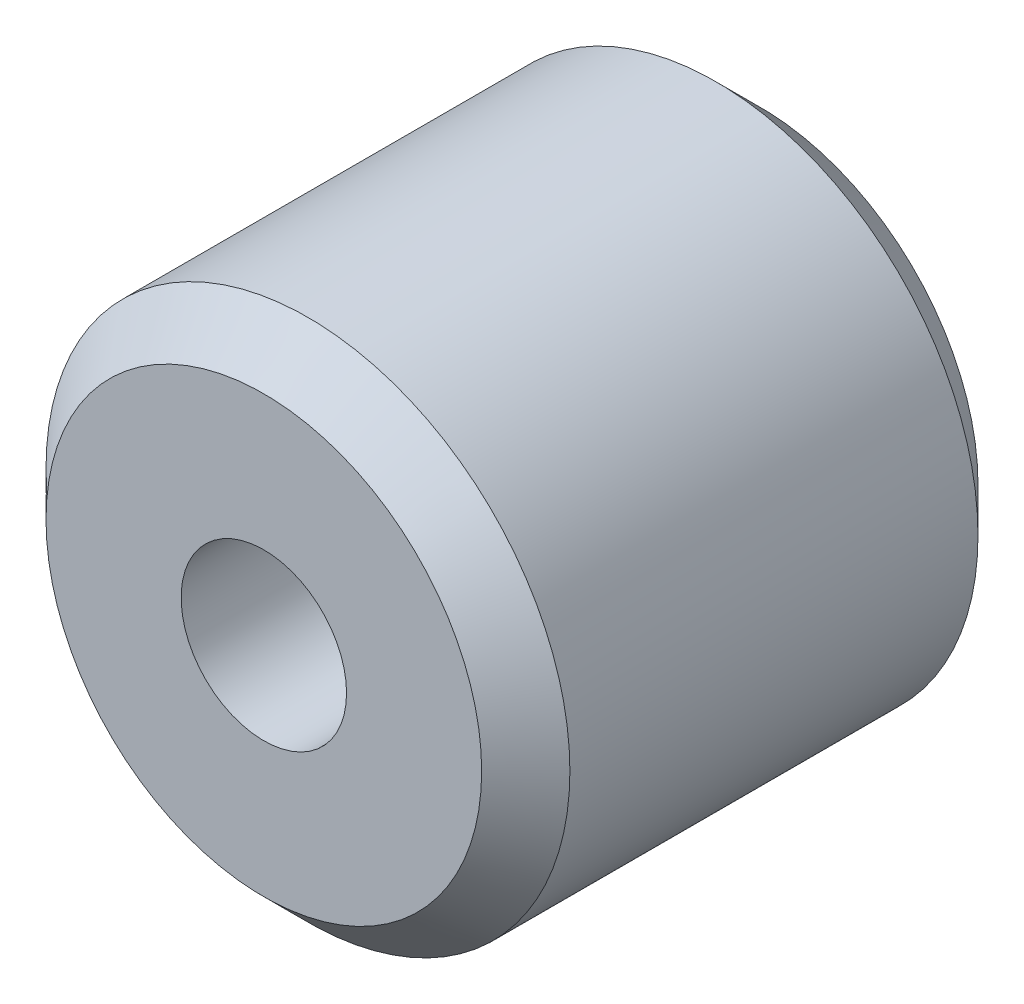
from build123d import *

# Parameters (mm, degrees)
SKETCH1_R           = 4.75
SKETCH1_R_2         = 1.5
BOSS_EXTRUDE1_DEPTH = 9
CHAMFER1_SIZE       = 0.8


with BuildPart() as part:
    # Sketch1 → Boss-Extrude1 (new body)
    with BuildSketch(Plane.XY):
        Circle(SKETCH1_R)
        Circle(SKETCH1_R_2, mode=Mode.SUBTRACT)
    extrude(amount=BOSS_EXTRUDE1_DEPTH)

    # Chamfer1
    chamfer1_edges = [part.edges().sort_by_distance(p)[0] for p in [
        (-4.75, 0, 0),
        (-4.75, 0, 9),
    ]]
    chamfer(chamfer1_edges, length=CHAMFER1_SIZE)


solid = part.part
